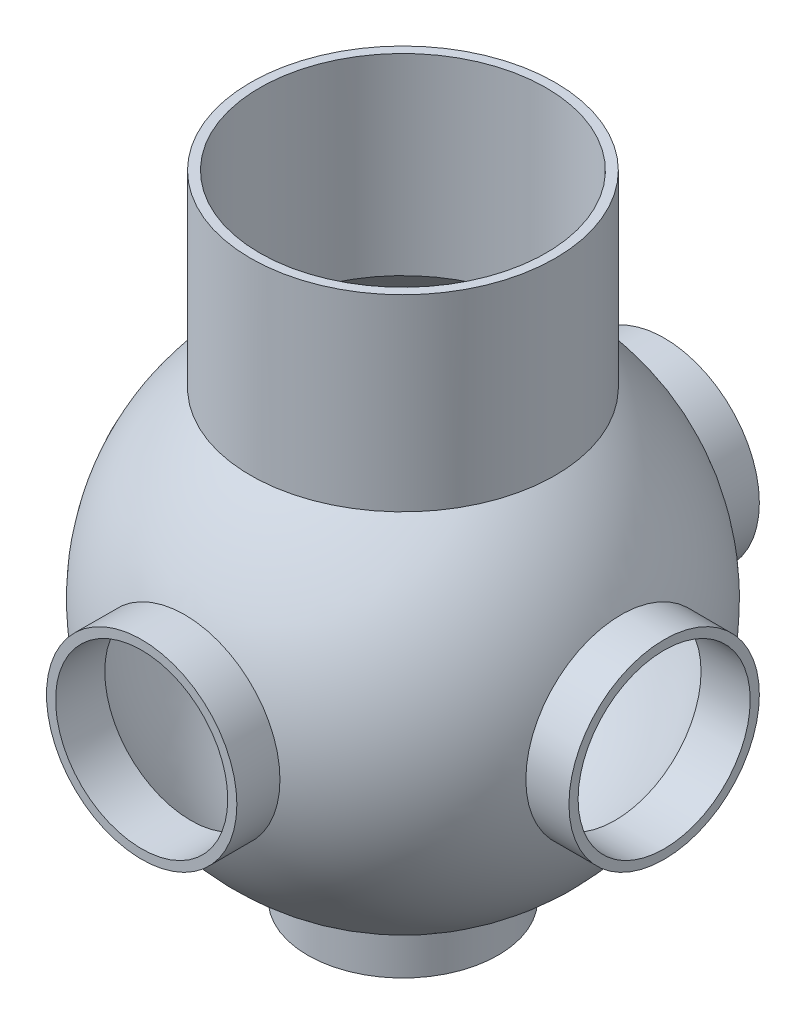
from build123d import *

# Parameters (mm, degrees)
SKETCH1_R                = 50.8
BOSS_EXTRUDE1_DEPTH      = 123.698
SKETCH31_R               = 31.75
BOSS_EXTRUDE6_DEPTH      = 87.122
SKETCH7_R                = 31.75
BOSS_EXTRUDE3_DEPTH      = 87.122
BOSS_EXTRUDE3_DEPTH_BACK = 87.122
SKETCH9_R                = 31.75
BOSS_EXTRUDE4_DEPTH      = 87.122
SKETCH11_R               = 19.05
BOSS_EXTRUDE5_DEPTH      = 83.82
SKETCH12_R               = 47.752
CUT_EXTRUDE4_DEPTH       = 124.6980001
SKETCH32_R               = 28.702
CUT_EXTRUDE8_DEPTH       = 88.1220001
SKETCH13_R               = 28.702
CUT_EXTRUDE5_DEPTH       = 88.122
CUT_EXTRUDE5_DEPTH_BACK  = 88.122
SKETCH14_R               = 28.702
CUT_EXTRUDE6_DEPTH       = 88.122
SKETCH15_R               = 17.399
CUT_EXTRUDE7_DEPTH       = 84.82


with BuildPart() as part:
    # Sketch1 → Boss-Extrude1 (new body)
    with BuildSketch(Plane(origin=(0, 0, 0), x_dir=(1, 0, 0), z_dir=(0, 1, 0))):
        Circle(SKETCH1_R)
    extrude(amount=BOSS_EXTRUDE1_DEPTH)

    # Sketch31 → Boss-Extrude6 (add)
    with BuildSketch(Plane(origin=(0, 0, 0), x_dir=(1, 0, 0), z_dir=(0, 1, 0))):
        Circle(SKETCH31_R)
    extrude(amount=-BOSS_EXTRUDE6_DEPTH)

    # Sketch7 → Boss-Extrude3 (add, two sides)
    with BuildSketch(Plane.XY) as boss_extrude3_sk:
        Circle(SKETCH7_R)
    extrude(amount=BOSS_EXTRUDE3_DEPTH)
    extrude(boss_extrude3_sk.sketch, amount=-BOSS_EXTRUDE3_DEPTH_BACK)

    # Sketch9 → Boss-Extrude4 (add)
    with BuildSketch(Plane(origin=(0, 0, 0), x_dir=(0, 0, -1), z_dir=(1, 0, 0))):
        Circle(SKETCH9_R)
    extrude(amount=BOSS_EXTRUDE4_DEPTH)

    # Sketch11 → Boss-Extrude5 (add)
    with BuildSketch(Plane(origin=(0, 0, 0), x_dir=(0, 0, -1), z_dir=(1, 0, 0))):
        Circle(SKETCH11_R)
    extrude(amount=-BOSS_EXTRUDE5_DEPTH)

    # Sketch23 → Revolve-Thin2 (revolve)
    with BuildSketch(Plane(origin=(0, 0, 0), x_dir=(1, 0, 0), z_dir=(0, 1, 0))):
        with BuildLine():
            ThreePointArc((-79.375, 0), (0, 79.375), (79.375, 0))
            Line((79.375, 0), (69.375, 0))
            ThreePointArc((69.375, 0), (0, 69.375), (-69.375, 0))
            Line((-69.375, 0), (-79.375, 0))
        make_face()
    revolve(axis=Axis((79.375, 0, 0), (-1, 0, 0)))

    # Sketch12 → Cut-Extrude4 (cut, through all)
    with BuildSketch(Plane(origin=(0, 0, 0), x_dir=(1, 0, 0), z_dir=(0, 1, 0))):
        Circle(SKETCH12_R)
    extrude(amount=CUT_EXTRUDE4_DEPTH, mode=Mode.SUBTRACT)

    # Sketch32 → Cut-Extrude8 (cut, through all)
    with BuildSketch(Plane(origin=(0, 0, 0), x_dir=(1, 0, 0), z_dir=(0, 1, 0))):
        Circle(SKETCH32_R)
    extrude(amount=-CUT_EXTRUDE8_DEPTH, mode=Mode.SUBTRACT)

    # Sketch13 → Cut-Extrude5 (cut, two sides)
    with BuildSketch(Plane.XY) as cut_extrude5_sk:
        Circle(SKETCH13_R)
    extrude(amount=CUT_EXTRUDE5_DEPTH, mode=Mode.SUBTRACT)
    extrude(cut_extrude5_sk.sketch, amount=-CUT_EXTRUDE5_DEPTH_BACK, mode=Mode.SUBTRACT)

    # Sketch14 → Cut-Extrude6 (cut, through all)
    with BuildSketch(Plane(origin=(0, 0, 0), x_dir=(0, 0, -1), z_dir=(1, 0, 0))):
        Circle(SKETCH14_R)
    extrude(amount=CUT_EXTRUDE6_DEPTH, mode=Mode.SUBTRACT)

    # Sketch15 → Cut-Extrude7 (cut, through all)
    with BuildSketch(Plane(origin=(0, 0, 0), x_dir=(0, 0, -1), z_dir=(1, 0, 0))):
        Circle(SKETCH15_R)
    extrude(amount=-CUT_EXTRUDE7_DEPTH, mode=Mode.SUBTRACT)

    # Sketch26 → Cut-Revolve1 (revolve, cut)
    with BuildSketch(Plane(origin=(0, 0, 0), x_dir=(1, 0, 0), z_dir=(0, 1, 0))):
        with BuildLine():
            Line((0, 76.327), (0, -76.327))
            ThreePointArc((0, -76.327), (76.327, 0), (0, 76.327))
        make_face()
    revolve(axis=Axis((0, 0, -76.327), (0, 0, 1)), mode=Mode.SUBTRACT)


solid = part.part
